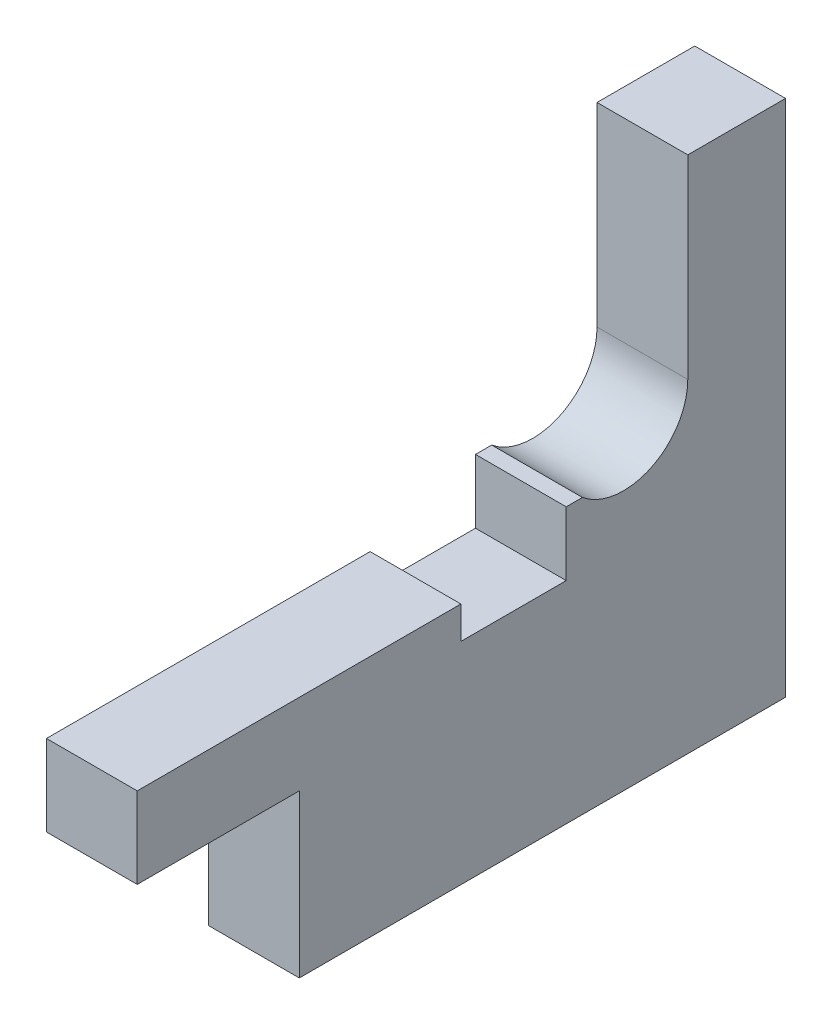
from build123d import *

# Parameters (mm, degrees)
BOSS_EXTRUDE1_DEPTH = 5.6


with BuildPart() as part:
    # Sketch1 → Boss-Extrude1 (new body)
    with BuildSketch(Plane(origin=(0, 0, 0), x_dir=(0, 0, -1), z_dir=(1, 0, 0))):
        with BuildLine():
            Line((3.96875, 0), (3.96875, 12))
            Line((3.96875, 12), (10, 12))
            Line((10, 12), (10, -20))
            Line((10, -20), (-20, -20))
            Line((-20, -20), (-20, -10))
            Line((-20, -10), (-30, -10))
            Line((-30, -10), (-30, -5))
            Line((-30, -5), (-10.03125, -5))
            Line((-10.03125, -5), (-10.03125, -7))
            Line((-10.03125, -7), (-3.53125, -7))
            Line((-3.53125, -7), (-3.53125, -3.056754815))
            Line((-3.53125, -3.056754815), (-2.53125, -3.056754815))
            ThreePointArc((-2.53125, -3.056754815), (1.68894614, -3.591439475), (3.96875, 0))
        make_face()
    extrude(amount=BOSS_EXTRUDE1_DEPTH)


solid = part.part
